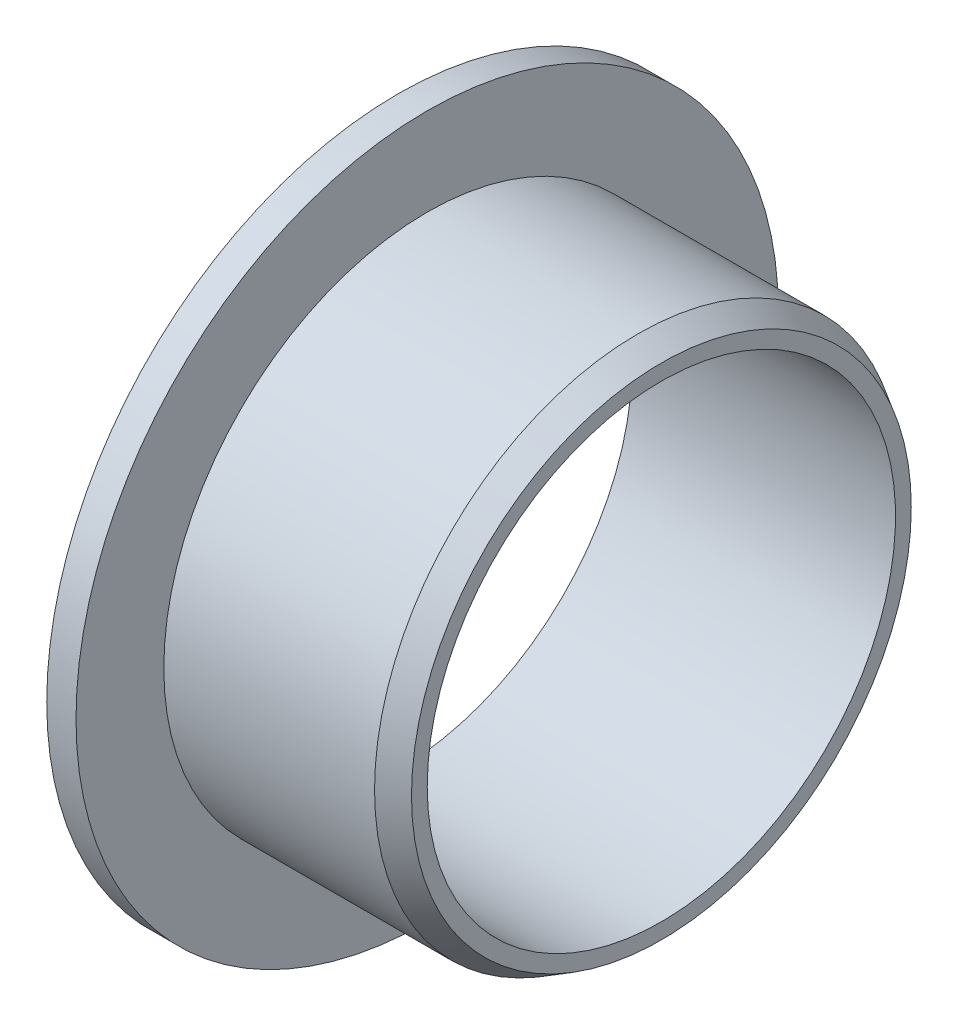
from build123d import *

# Parameters (mm, degrees)
SFAZOWANIE1_SIZE  = 0.8
SFAZOWANIE1_SIZE2 = 0.461880215


with BuildPart() as part:
    # Szkic1 → Obrót1 (revolve)
    with BuildSketch(Plane.XY):
        Polygon((0, 8), (9, 8), (9, 9), (1, 9), (1, 12), (0, 12), align=None)
    revolve(axis=Axis((0, 0, 0), (1, 0, 0)))

    # Sfazowanie1
    sfazowanie1_edges = [part.edges().sort_by_distance(p)[0] for p in [
        (9, -9, 0),
    ]]
    sfazowanie1_side = [part.faces().sort_by_distance(p)[0] for p in [
        (5, -9, 0),
    ]]
    chamfer(sfazowanie1_edges, length=SFAZOWANIE1_SIZE, length2=SFAZOWANIE1_SIZE2, reference=sfazowanie1_side[0])


solid = part.part
